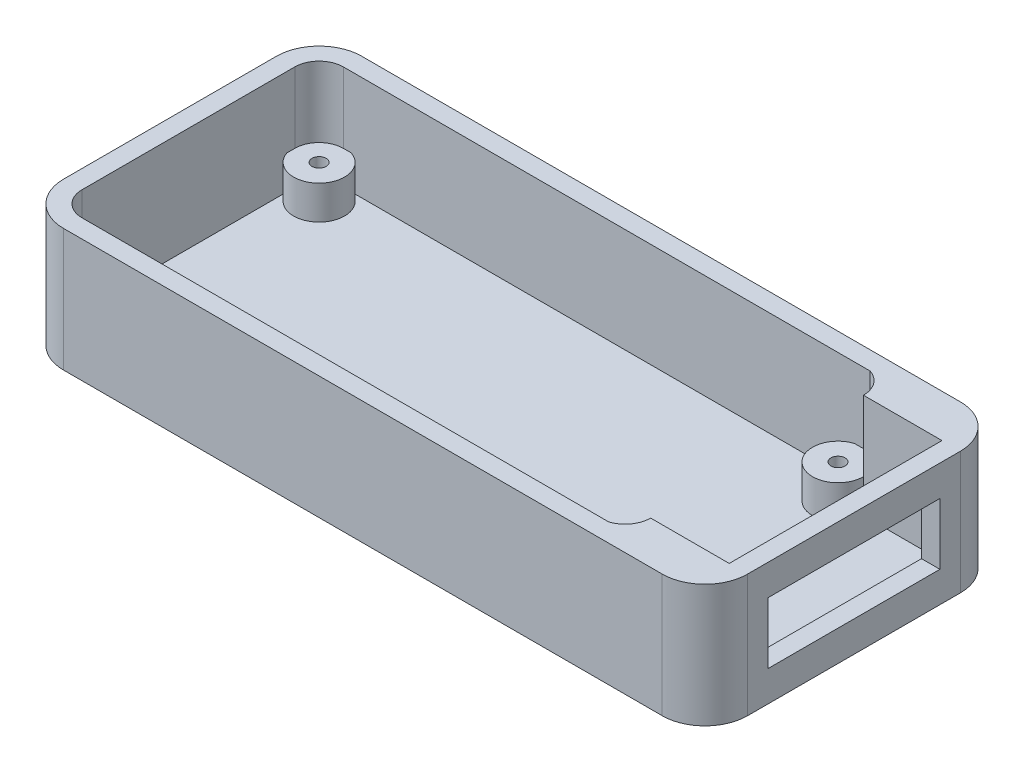
from build123d import *

# Parameters (mm, degrees)
EXTRUDE_4_DEPTH     = 10
EXTRUDE_3_DEPTH     = 1.5
CUT_EXTRUDE_2_REACH = 57.745
SKETCH_7_W          = 14
SKETCH_7_H          = 5
SKETCH_8_R          = 2.076581153
SKETCH_8_R_2        = 0.576581153
EXTRUDE_5_DEPTH     = 2.75
EXTRUDE_4_2_DEPTH   = 8.5


with BuildPart() as part:
    # 草图3 → Extrude 4 (new body)
    with BuildSketch(Plane(origin=(0, 0, 0), x_dir=(1, 0, 0), z_dir=(0, 1, 0))):
        with BuildLine():
            Line((50.567091694, 22.728702057), (1.78119206, 22.728702057))
            ThreePointArc((1.78119206, 22.728702057), (-0.678586397, 21.70982846), (-1.697459995, 19.250050003))
            Line((-1.697459995, 19.250050003), (-1.697459995, 1.905652309))
            ThreePointArc((-1.697459995, 1.905652309), (-0.678586397, -0.554126149), (1.78119206, -1.572999746))
            Line((1.78119206, -1.572999746), (50.567091694, -1.572999746))
            ThreePointArc((50.567091694, -1.572999746), (53.027823293, -0.553731345), (54.047091694, 1.907000254))
            Line((54.047091694, 1.907000254), (54.047091694, 19.248702057))
            ThreePointArc((54.047091694, 19.248702057), (53.027823293, 21.709433656), (50.567091694, 22.728702057))
        make_face()
        with BuildLine():
            Line((50.567091694, 21.228702057), (1.78119206, 21.228702057))
            ThreePointArc((1.78119206, 21.228702057), (0.382073774, 20.649168288), (-0.197459995, 19.250050003))
            Line((-0.197459995, 19.250050003), (-0.197459995, 1.905652309))
            ThreePointArc((-0.197459995, 1.905652309), (0.382073774, 0.506534023), (1.78119206, -0.072999746))
            Line((1.78119206, -0.072999746), (50.567091694, -0.072999746))
            ThreePointArc((50.567091694, -0.072999746), (51.967163121, 0.506928827), (52.547091694, 1.907000254))
            Line((52.547091694, 1.907000254), (52.547091694, 19.248702057))
            ThreePointArc((52.547091694, 19.248702057), (51.967163121, 20.648773484), (50.567091694, 21.228702057))
        make_face(mode=Mode.SUBTRACT)
    extrude(amount=EXTRUDE_4_DEPTH)

    # 草图3<5> → 凸台-拉伸3 (add)
    with BuildSketch(Plane(origin=(0, 0, 0), x_dir=(1, 0, 0), z_dir=(0, 1, 0))):
        with BuildLine():
            Line((50.567091694, 21.228702057), (1.78119206, 21.228702057))
            ThreePointArc((1.78119206, 21.228702057), (0.382073774, 20.649168288), (-0.197459995, 19.250050003))
            Line((-0.197459995, 19.250050003), (-0.197459995, 1.905652309))
            ThreePointArc((-0.197459995, 1.905652309), (0.382073774, 0.506534023), (1.78119206, -0.072999746))
            Line((1.78119206, -0.072999746), (50.567091694, -0.072999746))
            ThreePointArc((50.567091694, -0.072999746), (51.967163121, 0.506928827), (52.547091694, 1.907000254))
            Line((52.547091694, 1.907000254), (52.547091694, 19.248702057))
            ThreePointArc((52.547091694, 19.248702057), (51.967163121, 20.648773484), (50.567091694, 21.228702057))
        make_face()
    extrude(amount=EXTRUDE_3_DEPTH)

    # 草图7 → 切除-拉伸2 (cut, up to next)
    with BuildSketch(Plane(origin=(54.047091694, 0, 0), x_dir=(0, 0, -1), z_dir=(1, 0, 0)), mode=Mode.PRIVATE) as cut_extrude_2_sk1:
        with Locations((10.577851156, 5)):
            Rectangle(SKETCH_7_W, SKETCH_7_H)
    cut_extrude_2_tool1 = extrude(cut_extrude_2_sk1.sketch, amount=-CUT_EXTRUDE_2_REACH, mode=Mode.PRIVATE) & part.part
    add(cut_extrude_2_tool1.solids().sort_by_distance((54.047092, 5, -10.577851))[0], mode=Mode.SUBTRACT)

    # 草图8 → 拉伸-薄壁5 (add)
    with BuildSketch(Plane(origin=(0, 1.5, 0), x_dir=(1, 0, 0), z_dir=(0, 1, 0))):
        with Locations((44.069088138, 1.90500381)):
            Circle(SKETCH_8_R)
        with Locations((44.069088138, 1.90500381)):
            Circle(SKETCH_8_R_2, mode=Mode.SUBTRACT)
        with Locations((44.069088138, 19.250698501)):
            Circle(SKETCH_8_R)
        with Locations((44.069088138, 19.250698501)):
            Circle(SKETCH_8_R_2, mode=Mode.SUBTRACT)
        with Locations((1.780543561, 19.250698501)):
            Circle(SKETCH_8_R)
        with Locations((1.780543561, 19.250698501)):
            Circle(SKETCH_8_R_2, mode=Mode.SUBTRACT)
        with Locations((1.780543561, 1.90500381)):
            Circle(SKETCH_8_R)
        with Locations((1.780543561, 1.90500381)):
            Circle(SKETCH_8_R_2, mode=Mode.SUBTRACT)
    extrude(amount=EXTRUDE_5_DEPTH)

    # 草图9 → Extrude 4 2 (add)
    with BuildSketch(Plane(origin=(0, 1.5, 0), x_dir=(1, 0, 0), z_dir=(0, 1, 0))):
        with BuildLine():
            Line((44.70129951, -0.072999746), (50.567091694, -0.072999746))
            ThreePointArc((50.567091694, -0.072999746), (51.967163121, 0.506928827), (52.547091694, 1.907000254))
            Line((52.547091694, 1.907000254), (46.145668332, 1.907000254))
            ThreePointArc((46.145668332, 1.907000254), (45.746731704, 0.681197718), (44.70129951, -0.072999746))
        make_face()
        with BuildLine():
            Line((44.70129951, 21.228702057), (50.567091694, 21.228702057))
            ThreePointArc((50.567091694, 21.228702057), (51.967163121, 20.648773484), (52.547091694, 19.248702057))
            Line((52.547091694, 19.248702057), (46.145668332, 19.248702057))
            ThreePointArc((46.145668332, 19.248702057), (45.746731704, 20.474504593), (44.70129951, 21.228702057))
        make_face()
    extrude(amount=EXTRUDE_4_2_DEPTH)


solid = part.part
